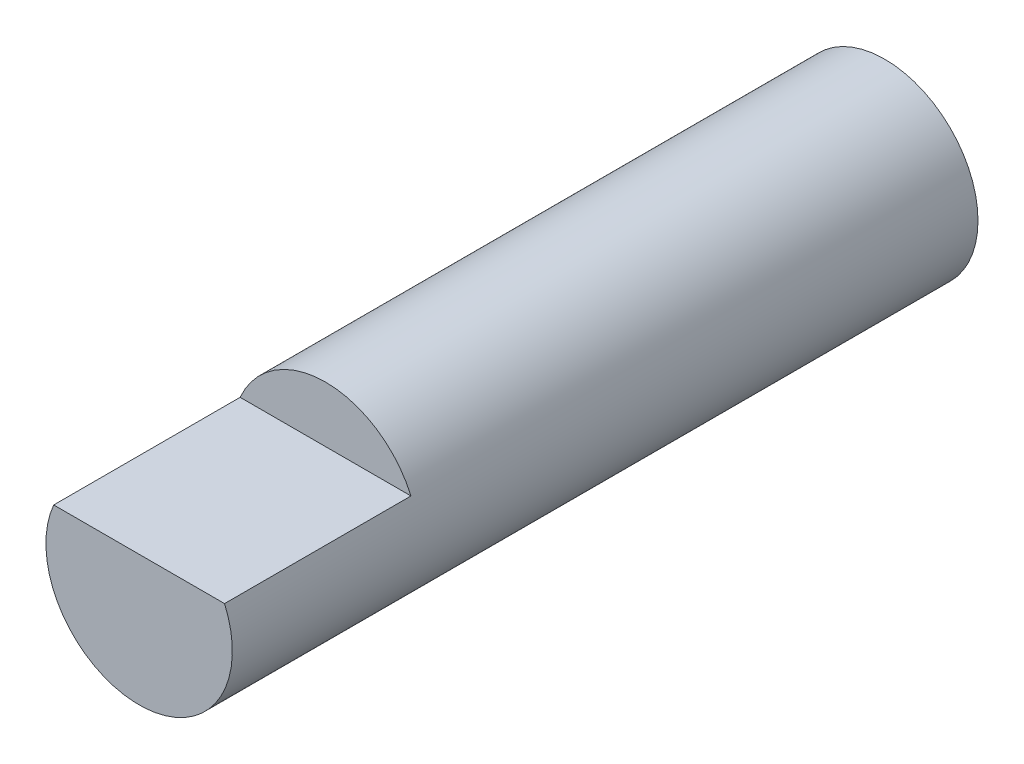
from build123d import *

# Parameters (mm, degrees)
SKETCH1_R           = 3.175
BOSS_EXTRUDE1_DEPTH = 25.4
CUT_EXTRUDE1_DEPTH  = 6.35


with BuildPart() as part:
    # Sketch1 → Boss-Extrude1 (new body)
    with BuildSketch(Plane.XY):
        Circle(SKETCH1_R)
    extrude(amount=BOSS_EXTRUDE1_DEPTH)

    # Sketch2 → Cut-Extrude1 (cut)
    with BuildSketch(Plane.XY.offset(25.4)):
        with BuildLine():
            Line((-6.35, 1.27), (6.35, 1.27))
            ThreePointArc((6.35, 1.27), (0, 7.62), (-6.35, 1.27))
        make_face()
    extrude(amount=-CUT_EXTRUDE1_DEPTH, mode=Mode.SUBTRACT)


solid = part.part
